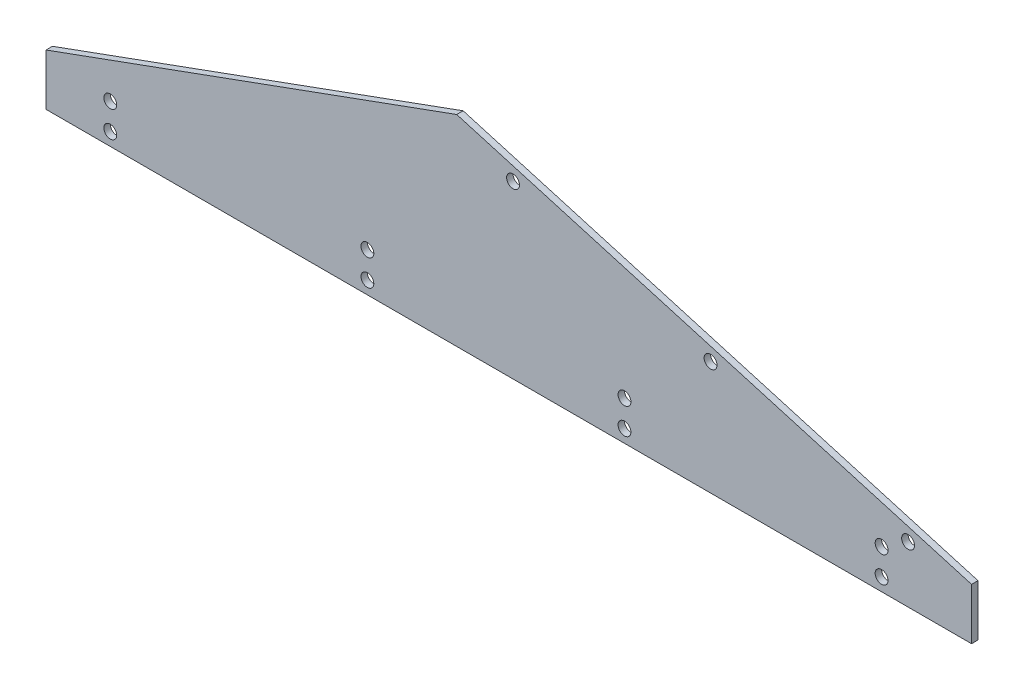
from build123d import *

# Parameters (mm, degrees)
SKETCH1_R           = 3.175
BOSS_EXTRUDE1_DEPTH = 3.175


with BuildPart() as part:
    # Sketch1 → Boss-Extrude1 (new body)
    with BuildSketch(Plane.XY):
        Polygon((0, 0), (457.2, 0), (457.2, 25.4), (202.879636828, 99.242148944), (0, 25.4), align=None)
        with Locations((230.698777852, 84.552587242)):
            Circle(SKETCH1_R, mode=Mode.SUBTRACT)
        with Locations((328.269214348, 56.222922191)):
            Circle(SKETCH1_R, mode=Mode.SUBTRACT)
        with Locations((425.839650845, 27.89325714)):
            Circle(SKETCH1_R, mode=Mode.SUBTRACT)
        with Locations((31.75, 19.301847719)):
            Circle(SKETCH1_R, mode=Mode.SUBTRACT)
        with Locations((31.75, 6.35)):
            Circle(SKETCH1_R, mode=Mode.SUBTRACT)
        with Locations((158.75, 19.301847719)):
            Circle(SKETCH1_R, mode=Mode.SUBTRACT)
        with Locations((285.75, 19.301847719)):
            Circle(SKETCH1_R, mode=Mode.SUBTRACT)
        with Locations((412.75, 19.301847719)):
            Circle(SKETCH1_R, mode=Mode.SUBTRACT)
        with Locations((158.75, 6.35)):
            Circle(SKETCH1_R, mode=Mode.SUBTRACT)
        with Locations((285.75, 6.35)):
            Circle(SKETCH1_R, mode=Mode.SUBTRACT)
        with Locations((412.75, 6.35)):
            Circle(SKETCH1_R, mode=Mode.SUBTRACT)
    extrude(amount=BOSS_EXTRUDE1_DEPTH)


solid = part.part
